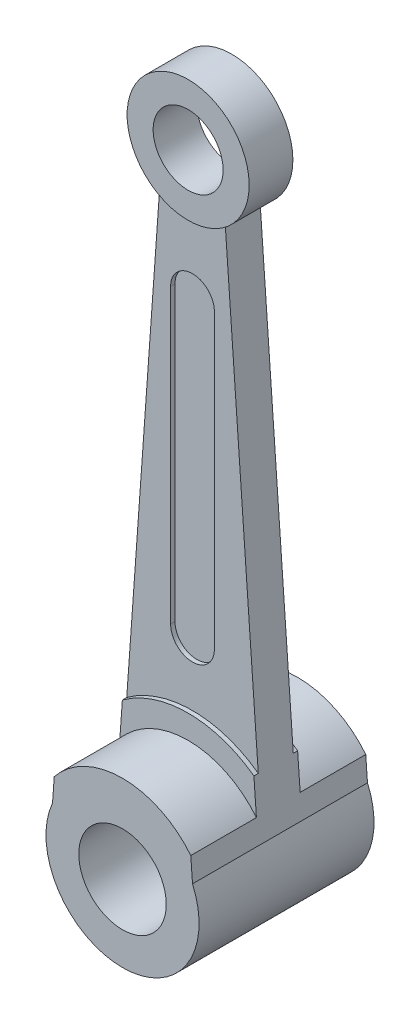
from build123d import *

# Parameters (mm, degrees)
SKETCH1_R                = 13.95
SKETCH1_R_2              = 8
BOSS_EXTRUDE1_DEPTH      = 5
SKETCH1_R_3              = 25.4
SKETCH1_R_4              = 10
BOSS_EXTRUDE1_2_DEPTH    = 5
BOSS_EXTRUDE2_DEPTH      = 4
BOSS_EXTRUDE3_DEPTH      = 3
BOSS_EXTRUDE4_DEPTH      = 15
BOSS_EXTRUDE4_DEPTH_BACK = 25
SKETCH3_R                = 20
SKETCH3_R_2              = 10
CUT_EXTRUDE1_DEPTH       = 27.5
SCALE2_SCALE             = 0.1


with BuildPart() as part:
    # Sketch1 → Boss-Extrude1 (new, symmetric)
    with BuildSketch(Plane.XY):
        with Locations((1.863247881, 104.324265103)):
            Circle(SKETCH1_R)
        with Locations((1.863247881, 104.324265103)):
            Circle(SKETCH1_R_2, mode=Mode.SUBTRACT)
    extrude(amount=BOSS_EXTRUDE1_DEPTH, both=True)



with BuildPart() as body_2:
    # Sketch1 → Boss-Extrude1 2 (new, symmetric)
    with BuildSketch(Plane.XY):
        with Locations((1.863247881, -32.575734897)):
            Circle(SKETCH1_R_3)
        with Locations((1.863247881, -32.575734897)):
            Circle(SKETCH1_R_4, mode=Mode.SUBTRACT)
    extrude(amount=BOSS_EXTRUDE1_2_DEPTH, both=True)


with BuildPart() as part_1:
    add(part.part)

    add(body_2.part)  # Boss-Extrude2 merges body 2
    # Sketch1_3 → Boss-Extrude2 (add, symmetric)
    with BuildSketch(Plane.XY):
        with BuildLine():
            ThreePointArc((9.363247881, 92.561931151), (1.863247881, 90.374265103), (-5.636752119, 92.561931151))
            Line((-5.636752119, 92.561931151), (-14.636752119, -13.264857133))
            ThreePointArc((-14.636752119, -13.264857133), (1.863247881, -7.175734897), (18.363247881, -13.264857133))
            Line((18.363247881, -13.264857133), (9.363247881, 92.561931151))
        make_face()
        with BuildLine():
            ThreePointArc((-3.136752119, 74.324265103), (1.863247881, 79.324265103), (6.863247881, 74.324265103))
            Line((6.863247881, 74.324265103), (6.863247881, 7.424265103))
            ThreePointArc((6.863247881, 7.424265103), (1.863247881, 2.424265103), (-3.136752119, 7.424265103))
            Line((-3.136752119, 7.424265103), (-3.136752119, 74.324265103))
        make_face(mode=Mode.SUBTRACT)
    extrude(amount=BOSS_EXTRUDE2_DEPTH, both=True)

    # Sketch1_4 → Boss-Extrude3 (add, symmetric)
    with BuildSketch(Plane.XY):
        with BuildLine():
            Line((6.863247881, 7.424265103), (6.863247881, 74.324265103))
            ThreePointArc((6.863247881, 74.324265103), (1.863247881, 79.324265103), (-3.136752119, 74.324265103))
            Line((-3.136752119, 74.324265103), (-3.136752119, 7.424265103))
            ThreePointArc((-3.136752119, 7.424265103), (1.863247881, 2.424265103), (6.863247881, 7.424265103))
        make_face()
    extrude(amount=BOSS_EXTRUDE3_DEPTH, both=True)

    # Sketch3 → Boss-Extrude4 (add, two sides: drawn at the far end of the back side and taken through both)
    with BuildSketch(Plane.XY.offset(5).offset(-BOSS_EXTRUDE4_DEPTH_BACK)):
        with Locations((1.863247881, -32.575734897)):
            Circle(SKETCH3_R)
        with Locations((1.863247881, -32.575734897)):
            Circle(SKETCH3_R_2, mode=Mode.SUBTRACT)
    extrude(amount=BOSS_EXTRUDE4_DEPTH + BOSS_EXTRUDE4_DEPTH_BACK)

    # Sketch4 → Cut-Extrude1 (cut, symmetric)
    with BuildSketch(Plane.XY):
        with BuildLine():
            Line((-5.636752119, 92.561931151), (-25.096940363, -6.510465862))
            ThreePointArc((-25.096940363, -6.510465862), (1.863247881, -70.075734897), (28.823436125, -6.510465862))
            Line((28.823436125, -6.510465862), (9.363247881, 92.561931151))
            Line((9.363247881, 92.561931151), (17.863247881, -25.487011458))
            ThreePointArc((17.863247881, -25.487011458), (1.863247881, -50.075734897), (-14.136752119, -25.487011458))
            Line((-14.136752119, -25.487011458), (-5.636752119, 92.561931151))
        make_face()
    extrude(amount=CUT_EXTRUDE1_DEPTH, both=True, mode=Mode.SUBTRACT)


with BuildPart() as part_2:
    # Scale2: scaled about (1.863247881, 1.50194237, 0)
    add(part_1.part.scale(SCALE2_SCALE).moved(Location((1.676923093, 1.351748133, 0))))


solid = part_2.part
